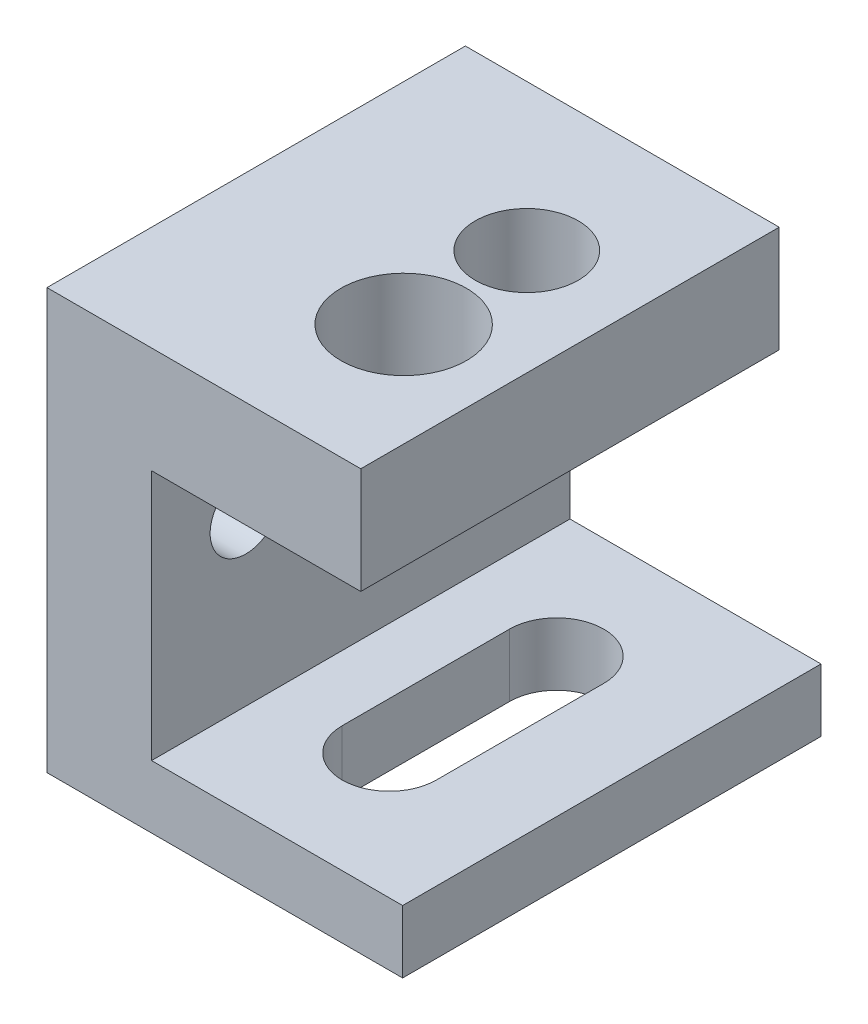
from build123d import *

# Parameters (mm, degrees)
SKETCH1_W            = 15
SKETCH1_H            = 20
BOSS_EXTRUDE1_DEPTH  = 5.08
SKETCH2_W            = 5
SKETCH2_H            = 20
BOSS_EXTRUDE2_DEPTH  = 15
M3_CLEARANCE_HOLE1_D = 3.4
SKETCH7_W            = 20
SKETCH7_H            = 3
BOSS_EXTRUDE3_DEPTH  = 12
SKETCH3_R            = 2.4638
CUT_EXTRUDE1_DEPTH   = 12
SKETCH4_R            = 3
CUT_EXTRUDE2_DEPTH   = 12
CUT_EXTRUDE3_DEPTH   = 12


with BuildPart() as part:
    # Sketch1 → Boss-Extrude1 (new body)
    with BuildSketch(Plane(origin=(0, 0, 0), x_dir=(1, 0, 0), z_dir=(0, 1, 0))):
        Rectangle(SKETCH1_W, SKETCH1_H)
    extrude(amount=BOSS_EXTRUDE1_DEPTH)

    # Sketch2 → Boss-Extrude2 (add)
    with BuildSketch(Plane(origin=(0, 0, 0), x_dir=(-1, 0, 0), z_dir=(0, -1, 0))):
        with Locations((5, 0)):
            Rectangle(SKETCH2_W, SKETCH2_H)
    extrude(amount=BOSS_EXTRUDE2_DEPTH)

    # M3 Clearance Hole1 (through all)
    with Locations(Plane(origin=(-2.5, 0, 0), x_dir=(0, 0, -1), z_dir=(1, 0, 0))):
        with Locations((5.5, -4), (-5.5, -4)):
            Hole(M3_CLEARANCE_HOLE1_D / 2)

    # Sketch7 → Boss-Extrude3 (add)
    with BuildSketch(Plane(origin=(-2.5, 0, 0), x_dir=(0, 0, -1), z_dir=(1, 0, 0))):
        with Locations((0, -13.5)):
            Rectangle(SKETCH7_W, SKETCH7_H)
    extrude(amount=BOSS_EXTRUDE3_DEPTH)

    # Sketch3 → Cut-Extrude1 (cut)
    with BuildSketch(Plane(origin=(0, 5.08, 0), x_dir=(1, 0, 0), z_dir=(0, 1, 0))):
        with Locations((2.435150465, 3)):
            Circle(SKETCH3_R)
    extrude(amount=-CUT_EXTRUDE1_DEPTH, mode=Mode.SUBTRACT)

    # Sketch4 → Cut-Extrude2 (cut)
    with BuildSketch(Plane(origin=(0, 5.08, 0), x_dir=(1, 0, 0), z_dir=(0, 1, 0))):
        with Locations((2.551153976, -3)):
            Circle(SKETCH4_R)
    extrude(amount=-CUT_EXTRUDE2_DEPTH, mode=Mode.SUBTRACT)

    # Sketch8 → Cut-Extrude3 (cut)
    with BuildSketch(Plane(origin=(0, -15, 0), x_dir=(-1, 0, 0), z_dir=(0, -1, 0))):
        with BuildLine():
            Line((-0.611529575, 4), (-0.611529575, -4))
            ThreePointArc((-0.611529575, -4), (-2.861529575, -6.25), (-5.111529575, -4))
            Line((-5.111529575, -4), (-5.111529575, 4))
            ThreePointArc((-5.111529575, 4), (-2.861529575, 6.25), (-0.611529575, 4))
        make_face()
    extrude(amount=-CUT_EXTRUDE3_DEPTH, mode=Mode.SUBTRACT)


solid = part.part
